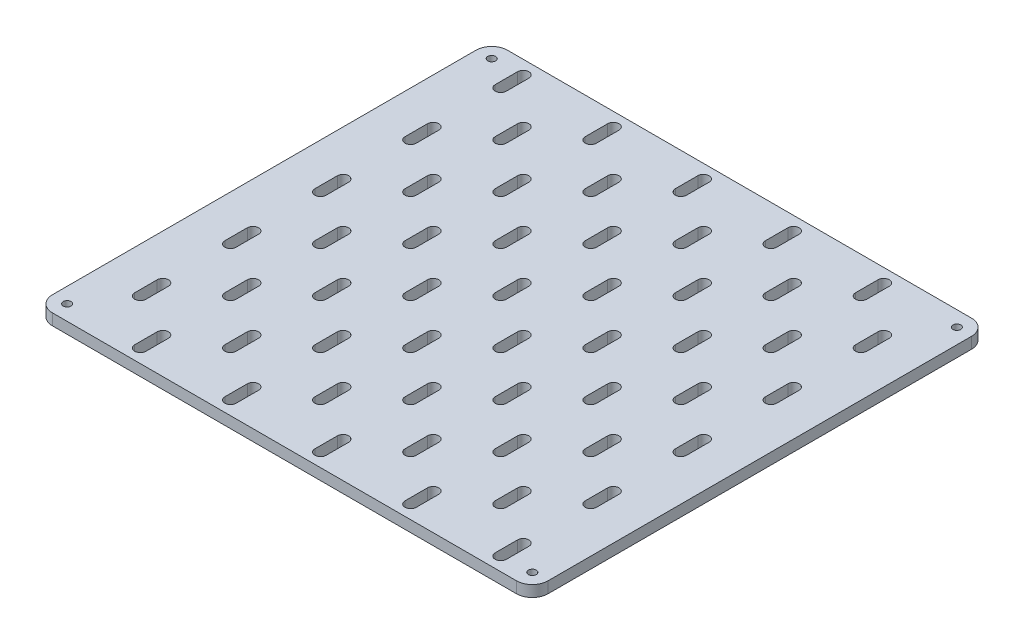
from build123d import *

# Parameters (mm, degrees)
SKETCH1_R                                           = 1.75
BOSS_EXTRUDE1_DEPTH                                 = 5
CSK_FOR_M3_COUNTERSUNK_FLAT_HEAD_SCREW1_D           = 3.2
CSK_FOR_M3_COUNTERSUNK_FLAT_HEAD_SCREW1_DEPTH       = 4
CSK_FOR_M3_COUNTERSUNK_FLAT_HEAD_SCREW1_CSINK_D     = 6.3
CSK_FOR_M3_COUNTERSUNK_FLAT_HEAD_SCREW1_CSINK_ANGLE = 90
CSK_FOR_M3_COUNTERSUNK_FLAT_HEAD_SCREW1_TIP         = 0.96137699


with BuildPart() as part:
    # Sketch1 → Boss-Extrude1 (new body)
    with BuildSketch(Plane(origin=(0, 0, 0), x_dir=(1, 0, 0), z_dir=(0, 1, 0))):
        with BuildLine():
            Line((7, 0), (213, 0))
            ThreePointArc((213, 0), (217.949747468, 2.050252532), (220, 7))
            Line((220, 7), (220, 195))
            ThreePointArc((220, 195), (217.949747468, 199.949747468), (213, 202))
            Line((213, 202), (7, 202))
            ThreePointArc((7, 202), (2.050252532, 199.949747468), (0, 195))
            Line((0, 195), (0, 7))
            ThreePointArc((0, 7), (2.050252532, 2.050252532), (7, 0))
        make_face()
        with Locations((6.75, 195.25)):
            Circle(SKETCH1_R, mode=Mode.SUBTRACT)
        with Locations((213.25, 195.25)):
            Circle(SKETCH1_R, mode=Mode.SUBTRACT)
        with Locations((213.25, 6.75)):
            Circle(SKETCH1_R, mode=Mode.SUBTRACT)
        with Locations((6.75, 6.75)):
            Circle(SKETCH1_R, mode=Mode.SUBTRACT)
        with BuildLine():
            Line((17.5, 186), (17.5, 196))
            ThreePointArc((17.5, 196), (20, 198.5), (22.5, 196))
            Line((22.5, 196), (22.5, 186))
            ThreePointArc((22.5, 186), (20, 183.5), (17.5, 186))
        make_face(mode=Mode.SUBTRACT)
        with BuildLine():
            Line((62.5, 186), (62.5, 196))
            ThreePointArc((62.5, 196), (60, 198.5), (57.5, 196))
            Line((57.5, 196), (57.5, 186))
            ThreePointArc((57.5, 186), (60, 183.5), (62.5, 186))
        make_face(mode=Mode.SUBTRACT)
        with BuildLine():
            Line((102.5, 186), (102.5, 196))
            ThreePointArc((102.5, 196), (100, 198.5), (97.5, 196))
            Line((97.5, 196), (97.5, 186))
            ThreePointArc((97.5, 186), (100, 183.5), (102.5, 186))
        make_face(mode=Mode.SUBTRACT)
        with BuildLine():
            Line((142.5, 186), (142.5, 196))
            ThreePointArc((142.5, 196), (140, 198.5), (137.5, 196))
            Line((137.5, 196), (137.5, 186))
            ThreePointArc((137.5, 186), (140, 183.5), (142.5, 186))
        make_face(mode=Mode.SUBTRACT)
        with BuildLine():
            Line((182.5, 186), (182.5, 196))
            ThreePointArc((182.5, 196), (180, 198.5), (177.5, 196))
            Line((177.5, 196), (177.5, 186))
            ThreePointArc((177.5, 186), (180, 183.5), (182.5, 186))
        make_face(mode=Mode.SUBTRACT)
        with BuildLine():
            Line((42.5, 176), (42.5, 166))
            ThreePointArc((42.5, 166), (40, 163.5), (37.5, 166))
            Line((37.5, 166), (37.5, 176))
            ThreePointArc((37.5, 176), (40, 178.5), (42.5, 176))
        make_face(mode=Mode.SUBTRACT)
        with BuildLine():
            Line((82.5, 176), (82.5, 166))
            ThreePointArc((82.5, 166), (80, 163.5), (77.5, 166))
            Line((77.5, 166), (77.5, 176))
            ThreePointArc((77.5, 176), (80, 178.5), (82.5, 176))
        make_face(mode=Mode.SUBTRACT)
        with BuildLine():
            Line((122.5, 176), (122.5, 166))
            ThreePointArc((122.5, 166), (120, 163.5), (117.5, 166))
            Line((117.5, 166), (117.5, 176))
            ThreePointArc((117.5, 176), (120, 178.5), (122.5, 176))
        make_face(mode=Mode.SUBTRACT)
        with BuildLine():
            Line((162.5, 176), (162.5, 166))
            ThreePointArc((162.5, 166), (160, 163.5), (157.5, 166))
            Line((157.5, 166), (157.5, 176))
            ThreePointArc((157.5, 176), (160, 178.5), (162.5, 176))
        make_face(mode=Mode.SUBTRACT)
        with BuildLine():
            Line((202.5, 176), (202.5, 166))
            ThreePointArc((202.5, 166), (200, 163.5), (197.5, 166))
            Line((197.5, 166), (197.5, 176))
            ThreePointArc((197.5, 176), (200, 178.5), (202.5, 176))
        make_face(mode=Mode.SUBTRACT)
        with BuildLine():
            Line((57.5, 146), (57.5, 156))
            ThreePointArc((57.5, 156), (60, 158.5), (62.5, 156))
            Line((62.5, 156), (62.5, 146))
            ThreePointArc((62.5, 146), (60, 143.5), (57.5, 146))
        make_face(mode=Mode.SUBTRACT)
        with BuildLine():
            Line((17.5, 146), (17.5, 156))
            ThreePointArc((17.5, 156), (20, 158.5), (22.5, 156))
            Line((22.5, 156), (22.5, 146))
            ThreePointArc((22.5, 146), (20, 143.5), (17.5, 146))
        make_face(mode=Mode.SUBTRACT)
        with BuildLine():
            Line((97.5, 146), (97.5, 156))
            ThreePointArc((97.5, 156), (100, 158.5), (102.5, 156))
            Line((102.5, 156), (102.5, 146))
            ThreePointArc((102.5, 146), (100, 143.5), (97.5, 146))
        make_face(mode=Mode.SUBTRACT)
        with BuildLine():
            Line((137.5, 146), (137.5, 156))
            ThreePointArc((137.5, 156), (140, 158.5), (142.5, 156))
            Line((142.5, 156), (142.5, 146))
            ThreePointArc((142.5, 146), (140, 143.5), (137.5, 146))
        make_face(mode=Mode.SUBTRACT)
        with BuildLine():
            Line((177.5, 146), (177.5, 156))
            ThreePointArc((177.5, 156), (180, 158.5), (182.5, 156))
            Line((182.5, 156), (182.5, 146))
            ThreePointArc((182.5, 146), (180, 143.5), (177.5, 146))
        make_face(mode=Mode.SUBTRACT)
        with BuildLine():
            Line((57.5, 106), (57.5, 116))
            ThreePointArc((57.5, 116), (60, 118.5), (62.5, 116))
            Line((62.5, 116), (62.5, 106))
            ThreePointArc((62.5, 106), (60, 103.5), (57.5, 106))
        make_face(mode=Mode.SUBTRACT)
        with BuildLine():
            Line((17.5, 106), (17.5, 116))
            ThreePointArc((17.5, 116), (20, 118.5), (22.5, 116))
            Line((22.5, 116), (22.5, 106))
            ThreePointArc((22.5, 106), (20, 103.5), (17.5, 106))
        make_face(mode=Mode.SUBTRACT)
        with BuildLine():
            Line((97.5, 106), (97.5, 116))
            ThreePointArc((97.5, 116), (100, 118.5), (102.5, 116))
            Line((102.5, 116), (102.5, 106))
            ThreePointArc((102.5, 106), (100, 103.5), (97.5, 106))
        make_face(mode=Mode.SUBTRACT)
        with BuildLine():
            Line((137.5, 106), (137.5, 116))
            ThreePointArc((137.5, 116), (140, 118.5), (142.5, 116))
            Line((142.5, 116), (142.5, 106))
            ThreePointArc((142.5, 106), (140, 103.5), (137.5, 106))
        make_face(mode=Mode.SUBTRACT)
        with BuildLine():
            Line((177.5, 106), (177.5, 116))
            ThreePointArc((177.5, 116), (180, 118.5), (182.5, 116))
            Line((182.5, 116), (182.5, 106))
            ThreePointArc((182.5, 106), (180, 103.5), (177.5, 106))
        make_face(mode=Mode.SUBTRACT)
        with BuildLine():
            Line((57.5, 66), (57.5, 76))
            ThreePointArc((57.5, 76), (60, 78.5), (62.5, 76))
            Line((62.5, 76), (62.5, 66))
            ThreePointArc((62.5, 66), (60, 63.5), (57.5, 66))
        make_face(mode=Mode.SUBTRACT)
        with BuildLine():
            Line((17.5, 66), (17.5, 76))
            ThreePointArc((17.5, 76), (20, 78.5), (22.5, 76))
            Line((22.5, 76), (22.5, 66))
            ThreePointArc((22.5, 66), (20, 63.5), (17.5, 66))
        make_face(mode=Mode.SUBTRACT)
        with BuildLine():
            Line((97.5, 66), (97.5, 76))
            ThreePointArc((97.5, 76), (100, 78.5), (102.5, 76))
            Line((102.5, 76), (102.5, 66))
            ThreePointArc((102.5, 66), (100, 63.5), (97.5, 66))
        make_face(mode=Mode.SUBTRACT)
        with BuildLine():
            Line((137.5, 66), (137.5, 76))
            ThreePointArc((137.5, 76), (140, 78.5), (142.5, 76))
            Line((142.5, 76), (142.5, 66))
            ThreePointArc((142.5, 66), (140, 63.5), (137.5, 66))
        make_face(mode=Mode.SUBTRACT)
        with BuildLine():
            Line((177.5, 66), (177.5, 76))
            ThreePointArc((177.5, 76), (180, 78.5), (182.5, 76))
            Line((182.5, 76), (182.5, 66))
            ThreePointArc((182.5, 66), (180, 63.5), (177.5, 66))
        make_face(mode=Mode.SUBTRACT)
        with BuildLine():
            Line((57.5, 26), (57.5, 36))
            ThreePointArc((57.5, 36), (60, 38.5), (62.5, 36))
            Line((62.5, 36), (62.5, 26))
            ThreePointArc((62.5, 26), (60, 23.5), (57.5, 26))
        make_face(mode=Mode.SUBTRACT)
        with BuildLine():
            Line((17.5, 26), (17.5, 36))
            ThreePointArc((17.5, 36), (20, 38.5), (22.5, 36))
            Line((22.5, 36), (22.5, 26))
            ThreePointArc((22.5, 26), (20, 23.5), (17.5, 26))
        make_face(mode=Mode.SUBTRACT)
        with BuildLine():
            Line((97.5, 26), (97.5, 36))
            ThreePointArc((97.5, 36), (100, 38.5), (102.5, 36))
            Line((102.5, 36), (102.5, 26))
            ThreePointArc((102.5, 26), (100, 23.5), (97.5, 26))
        make_face(mode=Mode.SUBTRACT)
        with BuildLine():
            Line((137.5, 26), (137.5, 36))
            ThreePointArc((137.5, 36), (140, 38.5), (142.5, 36))
            Line((142.5, 36), (142.5, 26))
            ThreePointArc((142.5, 26), (140, 23.5), (137.5, 26))
        make_face(mode=Mode.SUBTRACT)
        with BuildLine():
            Line((177.5, 26), (177.5, 36))
            ThreePointArc((177.5, 36), (180, 38.5), (182.5, 36))
            Line((182.5, 36), (182.5, 26))
            ThreePointArc((182.5, 26), (180, 23.5), (177.5, 26))
        make_face(mode=Mode.SUBTRACT)
        with BuildLine():
            Line((42.5, 136), (42.5, 126))
            ThreePointArc((42.5, 126), (40, 123.5), (37.5, 126))
            Line((37.5, 126), (37.5, 136))
            ThreePointArc((37.5, 136), (40, 138.5), (42.5, 136))
        make_face(mode=Mode.SUBTRACT)
        with BuildLine():
            Line((82.5, 136), (82.5, 126))
            ThreePointArc((82.5, 126), (80, 123.5), (77.5, 126))
            Line((77.5, 126), (77.5, 136))
            ThreePointArc((77.5, 136), (80, 138.5), (82.5, 136))
        make_face(mode=Mode.SUBTRACT)
        with BuildLine():
            Line((122.5, 136), (122.5, 126))
            ThreePointArc((122.5, 126), (120, 123.5), (117.5, 126))
            Line((117.5, 126), (117.5, 136))
            ThreePointArc((117.5, 136), (120, 138.5), (122.5, 136))
        make_face(mode=Mode.SUBTRACT)
        with BuildLine():
            Line((162.5, 136), (162.5, 126))
            ThreePointArc((162.5, 126), (160, 123.5), (157.5, 126))
            Line((157.5, 126), (157.5, 136))
            ThreePointArc((157.5, 136), (160, 138.5), (162.5, 136))
        make_face(mode=Mode.SUBTRACT)
        with BuildLine():
            Line((202.5, 136), (202.5, 126))
            ThreePointArc((202.5, 126), (200, 123.5), (197.5, 126))
            Line((197.5, 126), (197.5, 136))
            ThreePointArc((197.5, 136), (200, 138.5), (202.5, 136))
        make_face(mode=Mode.SUBTRACT)
        with BuildLine():
            Line((42.5, 96), (42.5, 86))
            ThreePointArc((42.5, 86), (40, 83.5), (37.5, 86))
            Line((37.5, 86), (37.5, 96))
            ThreePointArc((37.5, 96), (40, 98.5), (42.5, 96))
        make_face(mode=Mode.SUBTRACT)
        with BuildLine():
            Line((82.5, 96), (82.5, 86))
            ThreePointArc((82.5, 86), (80, 83.5), (77.5, 86))
            Line((77.5, 86), (77.5, 96))
            ThreePointArc((77.5, 96), (80, 98.5), (82.5, 96))
        make_face(mode=Mode.SUBTRACT)
        with BuildLine():
            Line((122.5, 96), (122.5, 86))
            ThreePointArc((122.5, 86), (120, 83.5), (117.5, 86))
            Line((117.5, 86), (117.5, 96))
            ThreePointArc((117.5, 96), (120, 98.5), (122.5, 96))
        make_face(mode=Mode.SUBTRACT)
        with BuildLine():
            Line((162.5, 96), (162.5, 86))
            ThreePointArc((162.5, 86), (160, 83.5), (157.5, 86))
            Line((157.5, 86), (157.5, 96))
            ThreePointArc((157.5, 96), (160, 98.5), (162.5, 96))
        make_face(mode=Mode.SUBTRACT)
        with BuildLine():
            Line((202.5, 96), (202.5, 86))
            ThreePointArc((202.5, 86), (200, 83.5), (197.5, 86))
            Line((197.5, 86), (197.5, 96))
            ThreePointArc((197.5, 96), (200, 98.5), (202.5, 96))
        make_face(mode=Mode.SUBTRACT)
        with BuildLine():
            Line((42.5, 56), (42.5, 46))
            ThreePointArc((42.5, 46), (40, 43.5), (37.5, 46))
            Line((37.5, 46), (37.5, 56))
            ThreePointArc((37.5, 56), (40, 58.5), (42.5, 56))
        make_face(mode=Mode.SUBTRACT)
        with BuildLine():
            Line((82.5, 56), (82.5, 46))
            ThreePointArc((82.5, 46), (80, 43.5), (77.5, 46))
            Line((77.5, 46), (77.5, 56))
            ThreePointArc((77.5, 56), (80, 58.5), (82.5, 56))
        make_face(mode=Mode.SUBTRACT)
        with BuildLine():
            Line((122.5, 56), (122.5, 46))
            ThreePointArc((122.5, 46), (120, 43.5), (117.5, 46))
            Line((117.5, 46), (117.5, 56))
            ThreePointArc((117.5, 56), (120, 58.5), (122.5, 56))
        make_face(mode=Mode.SUBTRACT)
        with BuildLine():
            Line((162.5, 56), (162.5, 46))
            ThreePointArc((162.5, 46), (160, 43.5), (157.5, 46))
            Line((157.5, 46), (157.5, 56))
            ThreePointArc((157.5, 56), (160, 58.5), (162.5, 56))
        make_face(mode=Mode.SUBTRACT)
        with BuildLine():
            Line((202.5, 56), (202.5, 46))
            ThreePointArc((202.5, 46), (200, 43.5), (197.5, 46))
            Line((197.5, 46), (197.5, 56))
            ThreePointArc((197.5, 56), (200, 58.5), (202.5, 56))
        make_face(mode=Mode.SUBTRACT)
        with BuildLine():
            Line((42.5, 16), (42.5, 6))
            ThreePointArc((42.5, 6), (40, 3.5), (37.5, 6))
            Line((37.5, 6), (37.5, 16))
            ThreePointArc((37.5, 16), (40, 18.5), (42.5, 16))
        make_face(mode=Mode.SUBTRACT)
        with BuildLine():
            Line((82.5, 16), (82.5, 6))
            ThreePointArc((82.5, 6), (80, 3.5), (77.5, 6))
            Line((77.5, 6), (77.5, 16))
            ThreePointArc((77.5, 16), (80, 18.5), (82.5, 16))
        make_face(mode=Mode.SUBTRACT)
        with BuildLine():
            Line((122.5, 16), (122.5, 6))
            ThreePointArc((122.5, 6), (120, 3.5), (117.5, 6))
            Line((117.5, 6), (117.5, 16))
            ThreePointArc((117.5, 16), (120, 18.5), (122.5, 16))
        make_face(mode=Mode.SUBTRACT)
        with BuildLine():
            Line((162.5, 16), (162.5, 6))
            ThreePointArc((162.5, 6), (160, 3.5), (157.5, 6))
            Line((157.5, 6), (157.5, 16))
            ThreePointArc((157.5, 16), (160, 18.5), (162.5, 16))
        make_face(mode=Mode.SUBTRACT)
        with BuildLine():
            Line((202.5, 16), (202.5, 6))
            ThreePointArc((202.5, 6), (200, 3.5), (197.5, 6))
            Line((197.5, 6), (197.5, 16))
            ThreePointArc((197.5, 16), (200, 18.5), (202.5, 16))
        make_face(mode=Mode.SUBTRACT)
    extrude(amount=BOSS_EXTRUDE1_DEPTH)

    # CSK for M3 Countersunk Flat Head Screw1
    with Locations(Plane(origin=(6.75, 0, -6.75), x_dir=(0, 0, -1), z_dir=(0, -1, 0))):
        with Locations((0, 0), (0, 206.5), (188.5, 0), (188.5, 206.5)):
            CounterSinkHole(CSK_FOR_M3_COUNTERSUNK_FLAT_HEAD_SCREW1_D / 2, CSK_FOR_M3_COUNTERSUNK_FLAT_HEAD_SCREW1_CSINK_D / 2, depth=CSK_FOR_M3_COUNTERSUNK_FLAT_HEAD_SCREW1_DEPTH, counter_sink_angle=CSK_FOR_M3_COUNTERSUNK_FLAT_HEAD_SCREW1_CSINK_ANGLE)
            with Locations((0, 0, -(CSK_FOR_M3_COUNTERSUNK_FLAT_HEAD_SCREW1_DEPTH + CSK_FOR_M3_COUNTERSUNK_FLAT_HEAD_SCREW1_TIP / 2))):  # 118° drill point
                Cone(0, CSK_FOR_M3_COUNTERSUNK_FLAT_HEAD_SCREW1_D / 2, CSK_FOR_M3_COUNTERSUNK_FLAT_HEAD_SCREW1_TIP, mode=Mode.SUBTRACT)


solid = part.part
